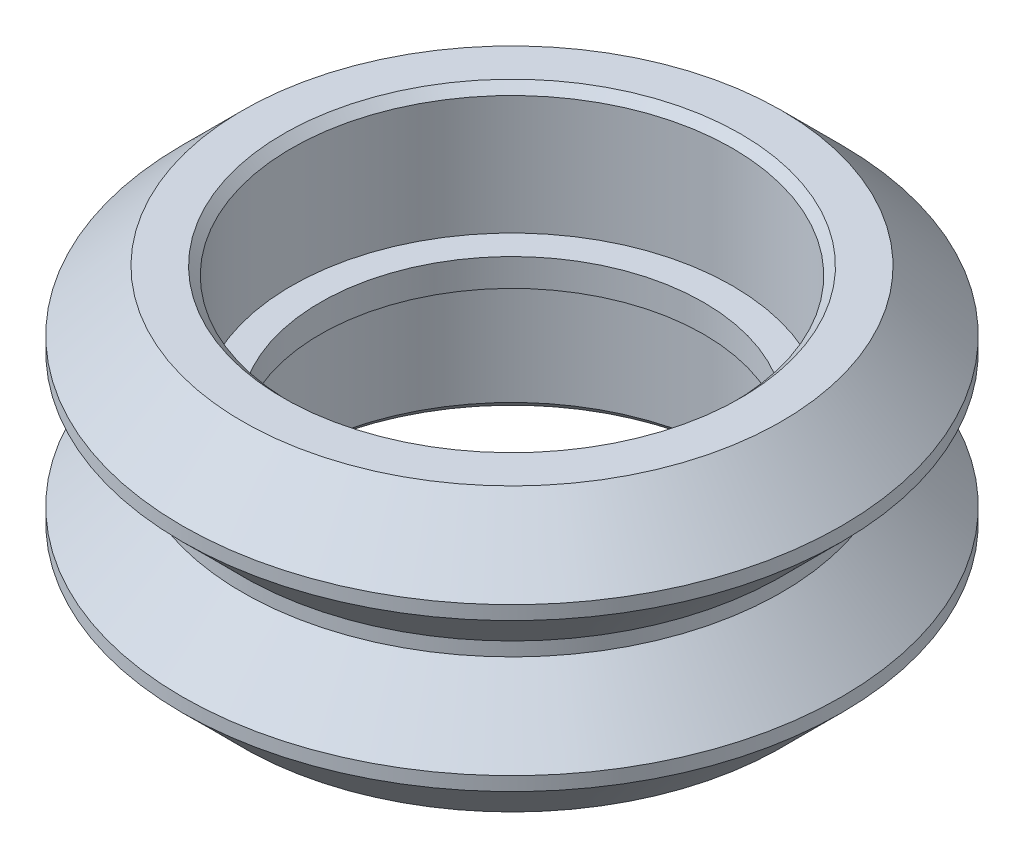
from build123d import *


with BuildPart() as part:
    # Sketch1 → Revolution1 (revolve)
    with BuildSketch(Plane.XY):
        Polygon((7.987, 9.93), (7.987, 5.615), (6.945, 5.615), (6.945, 4.615), (7.987, 4.615), (7.987, 0.3), (8.287, 0), (9.7625, 0), (11.945, 2.1825), (11.945, 2.6825), (9.7625, 4.865), (9.7625, 5.365), (11.945, 7.5475), (11.945, 8.0475), (9.7625, 10.23), (8.287, 10.23), align=None)
    revolve(axis=Axis((0, 0, 0), (0, 1, 0)))


solid = part.part
